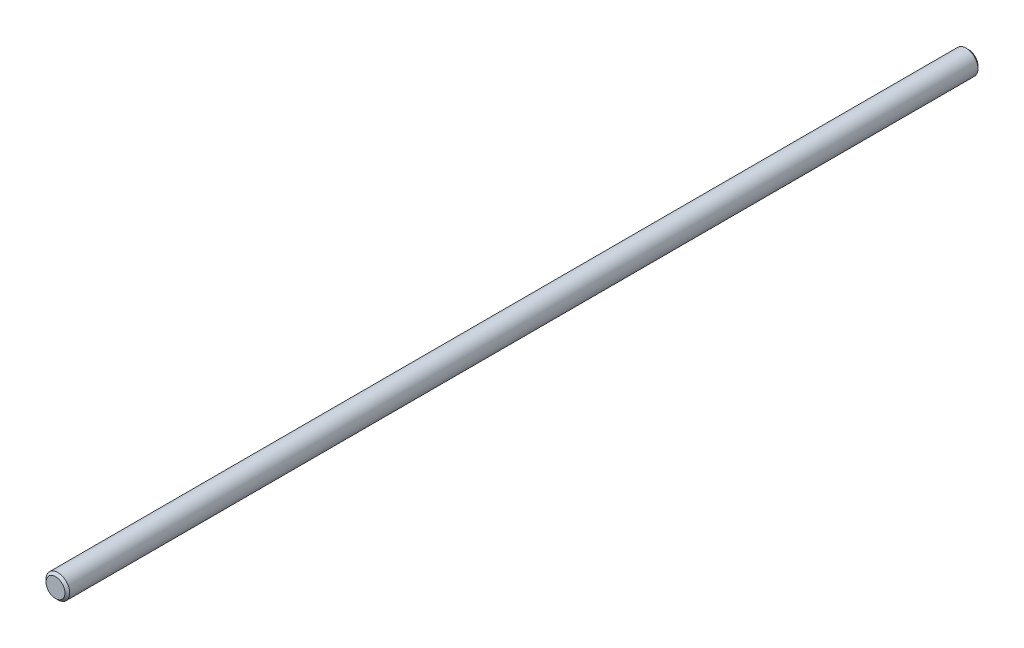
from build123d import *

# Parameters (mm, degrees)
SKETCH1_R           = 3.175
BOSS_EXTRUDE1_DEPTH = 122.2375
CHAMFER1_SIZE       = 0.635


with BuildPart() as part:
    # Sketch1 → Boss-Extrude1 (new body, symmetric)
    with BuildSketch(Plane.XY):
        Circle(SKETCH1_R)
    extrude(amount=BOSS_EXTRUDE1_DEPTH, both=True)

    # Chamfer1
    chamfer1_edges = [part.edges().sort_by_distance(p)[0] for p in [
        (-3.175, 0, -122.2375),
        (-3.175, 0, 122.2375),
    ]]
    chamfer(chamfer1_edges, length=CHAMFER1_SIZE)


solid = part.part
